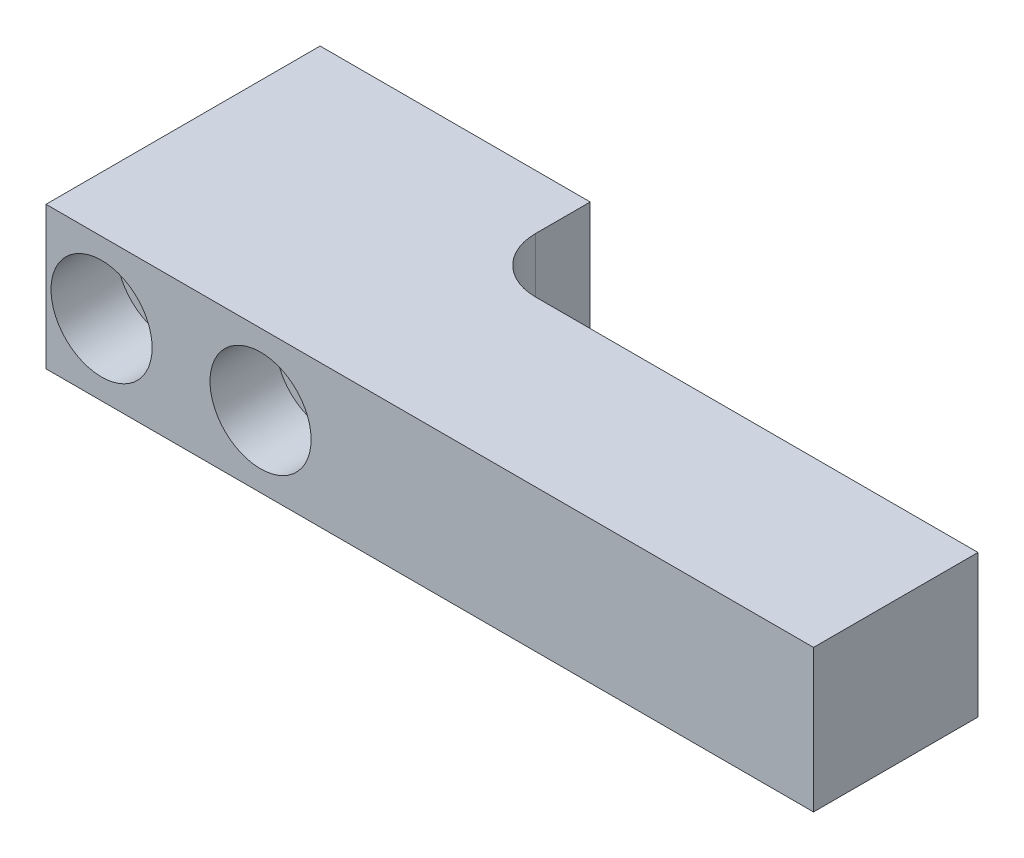
from build123d import *

# Parameters (mm, degrees)
SKETCH1_W           = 24.634
SKETCH1_H           = 13
BOSS_EXTRUDE1_DEPTH = 10
SKETCH4_W           = 70
SKETCH4_H           = 13
BOSS_EXTRUDE4_DEPTH = 15
FILLET2_R           = 5
SKETCH11_R          = 2.68
CUT_EXTRUDE3_DEPTH  = 26
SKETCH12_R          = 4.61
CUT_EXTRUDE4_DEPTH  = 6


with BuildPart() as part:
    # Sketch1 → Boss-Extrude1 (new body)
    with BuildSketch(Plane.XY):
        with Locations((12.317, 6.5)):
            Rectangle(SKETCH1_W, SKETCH1_H)
    extrude(amount=BOSS_EXTRUDE1_DEPTH)

    # Sketch4 → Boss-Extrude4 (add)
    with BuildSketch(Plane.XY.offset(10)):
        with Locations((35, 6.5)):
            Rectangle(SKETCH4_W, SKETCH4_H)
    extrude(amount=BOSS_EXTRUDE4_DEPTH)

    # Fillet2
    fillet2_edges = [part.edges().sort_by_distance(p)[0] for p in [
        (24.634, 6.5, 10),
    ]]
    fillet(fillet2_edges, radius=FILLET2_R)

    # Sketch11 → Cut-Extrude3 (cut, through all)
    with BuildSketch(Plane(origin=(0, 0, 0), x_dir=(-1, 0, 0), z_dir=(0, 0, -1))):
        with Locations((-5.067, 6.5)):
            Circle(SKETCH11_R)
        with Locations((-19.567, 6.5)):
            Circle(SKETCH11_R)
    extrude(amount=-CUT_EXTRUDE3_DEPTH, mode=Mode.SUBTRACT)

    # Sketch12 → Cut-Extrude4 (cut)
    with BuildSketch(Plane.XY.offset(25)):
        with Locations((5.067, 6.5)):
            Circle(SKETCH12_R)
        with Locations((19.567, 6.5)):
            Circle(SKETCH12_R)
    extrude(amount=-CUT_EXTRUDE4_DEPTH, mode=Mode.SUBTRACT)


solid = part.part
